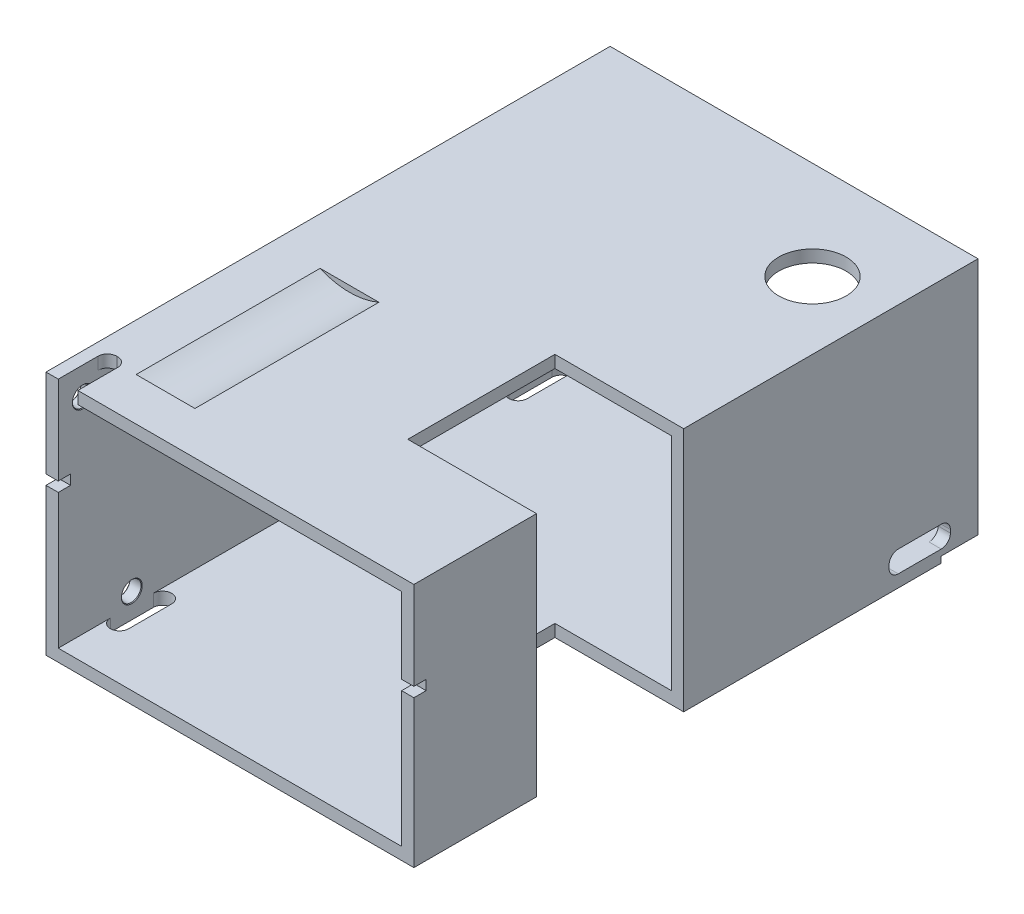
from build123d import *

# Parameters (mm, degrees)
SKETCH_1_W                 = 60
SKETCH_1_H                 = 40
SKETCH_1_W_2               = 56
SKETCH_1_H_2               = 36
EXTRUDE_1_DEPTH            = 92
SKETCH_3_W                 = 21
SKETCH_3_H                 = 24
CUT_EXTRUDE_2_DEPTH        = 41
SKETCH_9_R                 = 3.25
CUT_EXTRUDE_4_DEPTH        = 4
CUT_EXTRUDE_5_REACH        = 62
CUT_EXTRUDE_START          = -55
CUT_EXTRUDE_8_DEPTH        = 30
CUT_EXTRUDE_9_REACH        = 42
SKETCH_17_R                = 5.5
SKETCH_18_W                = 6
SKETCH_18_H                = 1
CUT_EXTRUDE_10_DEPTH       = 61
CUT_EXTRUDE_11_REACH       = 42
HOLE_WIZARD_M31_AT_2_COUNT = 2
HOLE_WIZARD_M31_AT_2_PITCH = 79.506289059
HOLE_WIZARD_M31_AT_3_COUNT = 2
HOLE_WIZARD_M31_AT_3_PITCH = 32.5
CUT_EXTRUDE_12_DEPTH       = 61
CUT_EXTRUDE_13_REACH       = 42


with BuildPart() as part:
    # Эскиз1 → Бобышка-Вытянуть1 (new body)
    with BuildSketch(Plane.XY):
        Rectangle(SKETCH_1_W, SKETCH_1_H)
        Rectangle(SKETCH_1_W_2, SKETCH_1_H_2, mode=Mode.SUBTRACT)
    extrude(amount=EXTRUDE_1_DEPTH)

    # Эскиз3 → Вырез-Вытянуть2 (cut, through all)
    with BuildSketch(Plane(origin=(0, 20, 0), x_dir=(1, 0, 0), z_dir=(0, 1, 0))):
        with Locations((19.5, -60)):
            Rectangle(SKETCH_3_W, SKETCH_3_H)
    extrude(amount=-CUT_EXTRUDE_2_DEPTH, mode=Mode.SUBTRACT)

    # Эскиз9 → Вырез-Вытянуть4 (cut)
    with BuildSketch(Plane.XZ.offset(20)):
        with Locations((21, 11)):
            Circle(SKETCH_9_R)
    extrude(amount=-CUT_EXTRUDE_4_DEPTH, mode=Mode.SUBTRACT)

    # Эскиз10 → Вырез-Вытянуть5 (cut, up to next)
    with BuildSketch(Plane(origin=(30, 0, 0), x_dir=(0, 0, -1), z_dir=(1, 0, 0)), mode=Mode.PRIVATE) as cut_extrude_5_sk1:
        with BuildLine():
            Line((-6, -14.5), (-13, -14.5))
            ThreePointArc((-13, -14.5), (-14.060660172, -14.939339828), (-14.5, -16))
            Line((-14.5, -16), (-14.5, -16.5))
            ThreePointArc((-14.5, -16.5), (-14.060660172, -17.560660172), (-13, -18))
            Line((-13, -18), (-6, -18))
            ThreePointArc((-6, -18), (-4.939339828, -17.560660172), (-4.5, -16.5))
            Line((-4.5, -16.5), (-4.5, -16))
            ThreePointArc((-4.5, -16), (-4.939339828, -14.939339828), (-6, -14.5))
        make_face()
    cut_extrude_5_tool1 = extrude(cut_extrude_5_sk1.sketch, amount=-CUT_EXTRUDE_5_REACH, mode=Mode.PRIVATE) & part.part
    add(cut_extrude_5_tool1.solids().sort_by_distance((30, -16.25, 9.5))[0], mode=Mode.SUBTRACT)

    # Эскиз16 → Вырез-Вытянуть8 (cut)
    with BuildSketch(Plane(origin=(0, 0, 0), x_dir=(-1, 0, 0), z_dir=(0, 0, -1)).offset(CUT_EXTRUDE_START)):
        with BuildLine():
            Line((22.295831523, 20), (12.704168477, 20))
            ThreePointArc((12.704168477, 20), (17.5, 19), (22.295831523, 20))
        make_face()
    extrude(amount=-CUT_EXTRUDE_8_DEPTH, mode=Mode.SUBTRACT)

    # Эскиз17 → Вырез-Вытянуть9 (cut, up to next)
    with BuildSketch(Plane(origin=(0, 20, 0), x_dir=(1, 0, 0), z_dir=(0, 1, 0)), mode=Mode.PRIVATE) as cut_extrude_9_sk1:
        with Locations((19, -16)):
            Circle(SKETCH_17_R)
    cut_extrude_9_tool1 = extrude(cut_extrude_9_sk1.sketch, amount=-CUT_EXTRUDE_9_REACH, mode=Mode.PRIVATE) & part.part
    add(cut_extrude_9_tool1.solids().sort_by_distance((19, 20, 16))[0], mode=Mode.SUBTRACT)

    # Эскиз18 → Вырез-Вытянуть10 (cut, through all)
    with BuildSketch(Plane(origin=(30, 0, 0), x_dir=(0, 0, -1), z_dir=(1, 0, 0))):
        with Locations((-3, -19.5)):
            Rectangle(SKETCH_18_W, SKETCH_18_H)
    extrude(amount=-CUT_EXTRUDE_10_DEPTH, mode=Mode.SUBTRACT)

    # Эскиз19 → Вырез-Вытянуть11 (cut, up to next)
    with BuildSketch(Plane(origin=(0, 20, 0), x_dir=(1, 0, 0), z_dir=(0, 1, 0)), mode=Mode.PRIVATE) as cut_extrude_11_sk1:
        with BuildLine():
            Line((-28, -85.5), (-28, -92))
            Line((-28, -92), (-24.8, -92))
            Line((-24.8, -92), (-24.8, -85.5))
            ThreePointArc((-24.8, -85.5), (-25.239339828, -84.439339828), (-26.3, -84))
            Line((-26.3, -84), (-26.5, -84))
            ThreePointArc((-26.5, -84), (-27.560660172, -84.439339828), (-28, -85.5))
        make_face()
    cut_extrude_11_tool1 = extrude(cut_extrude_11_sk1.sketch, amount=-CUT_EXTRUDE_11_REACH, mode=Mode.PRIVATE) & part.part
    add(cut_extrude_11_tool1.solids().sort_by_distance((-26.4, 20, 88.143673))[0], mode=Mode.SUBTRACT)

    # Эскиз20 → Hole Wizard M31 (revolve, cut)
    with BuildSketch(Plane(origin=(-30, 15.5, 88), x_dir=(0, 0, 1), z_dir=(0, 1, 0))):
        Polygon((0, 0), (0, 2), (1.7, 2), (1.6, 1.9), (1.6, 0.1), (1.7, 0), align=None)
    hole_wizard_m31 = revolve(axis=Axis((-36.35, 15.5, 88), (1, 0, 0)), mode=Mode.SUBTRACT)

    # Hole Wizard M31 at 2: Hole Wizard M31 ×2
    with Locations(*[Vector(0, -0.396195073, -0.91816636) * (i * HOLE_WIZARD_M31_AT_2_PITCH) for i in range(1, HOLE_WIZARD_M31_AT_2_COUNT)]):
        add(hole_wizard_m31, mode=Mode.SUBTRACT)

    # Hole Wizard M31 at 3: Hole Wizard M31 ×2
    with Locations(*[Vector(0, -0.969230769, -0.246153846) * (i * HOLE_WIZARD_M31_AT_3_PITCH) for i in range(1, HOLE_WIZARD_M31_AT_3_COUNT)]):
        add(hole_wizard_m31, mode=Mode.SUBTRACT)

    # Эскиз22 → Вырез-Вытянуть12 (cut, through all)
    with BuildSketch(Plane.ZY.offset(30)):
        Polygon((292.990680401, 5.6), (92, 5.6), (90, 5.6), (90, 4), (92, 4), (292.990680401, 4), (694.972041203, 4), (694.972041203, 5.6), align=None)
    extrude(amount=-CUT_EXTRUDE_12_DEPTH, mode=Mode.SUBTRACT)

    # Эскиз23 → Вырез-Вытянуть13 (cut, up to next)
    with BuildSketch(Plane.XZ.offset(20), mode=Mode.PRIVATE) as cut_extrude_13_sk1:
        with BuildLine():
            Line((-25, 11.5), (-25, 18.5))
            ThreePointArc((-25, 18.5), (-26.5, 20), (-28, 18.5))
            Line((-28, 18.5), (-28, 11.5))
            ThreePointArc((-28, 11.5), (-26.5, 10), (-25, 11.5))
        make_face()
    cut_extrude_13_tool1 = extrude(cut_extrude_13_sk1.sketch, amount=-CUT_EXTRUDE_13_REACH, mode=Mode.PRIVATE) & part.part
    add(cut_extrude_13_tool1.solids().sort_by_distance((-26.5, -20, 15))[0], mode=Mode.SUBTRACT)
    # Эскиз23 → Вырез-Вытянуть13 (cut, up to next)
    with BuildSketch(Plane.XZ.offset(20), mode=Mode.PRIVATE) as cut_extrude_13_sk2:
        with BuildLine():
            Line((-28, 83.5), (-28, 76.5))
            ThreePointArc((-28, 76.5), (-26.5, 75), (-25, 76.5))
            Line((-25, 76.5), (-25, 83.5))
            ThreePointArc((-25, 83.5), (-26.5, 85), (-28, 83.5))
        make_face()
    cut_extrude_13_tool2 = extrude(cut_extrude_13_sk2.sketch, amount=-CUT_EXTRUDE_13_REACH, mode=Mode.PRIVATE) & part.part
    add(cut_extrude_13_tool2.solids().sort_by_distance((-26.5, -20, 80))[0], mode=Mode.SUBTRACT)


solid = part.part
